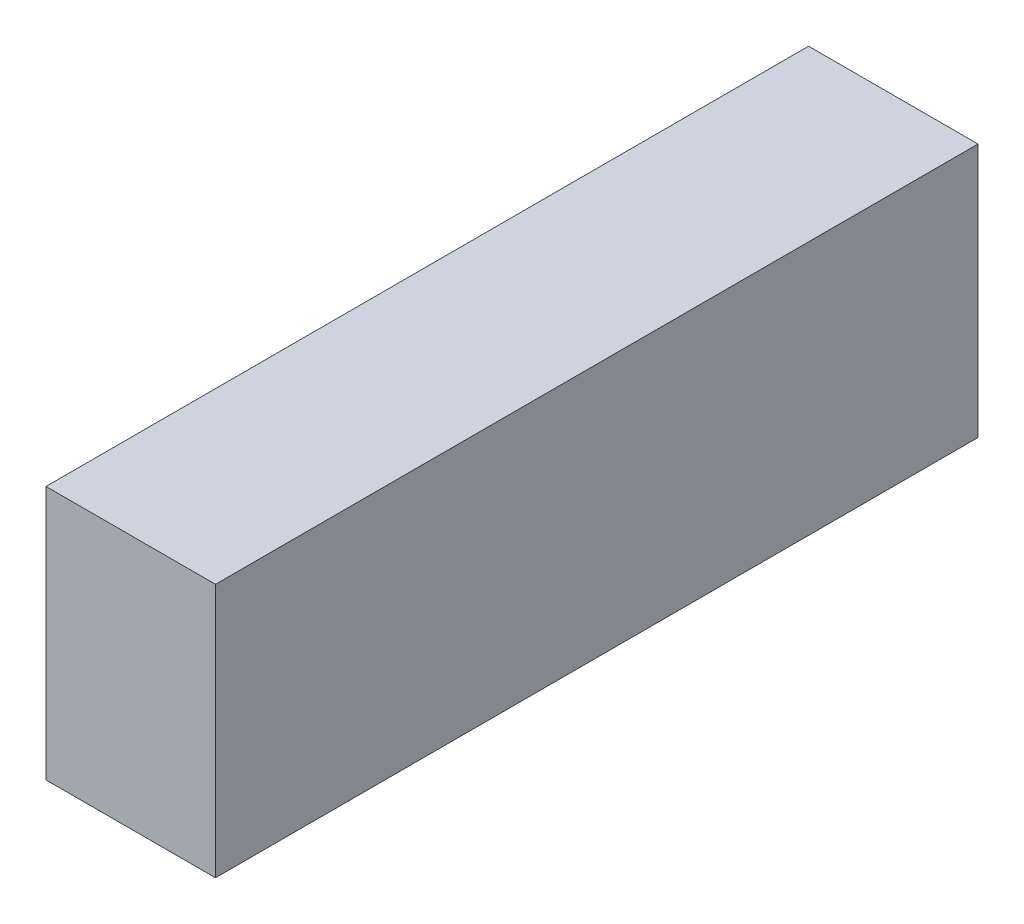
from build123d import *

# Parameters (mm, degrees)
SKETCH1_W           = 8.466666666
SKETCH1_H           = 12.7
BOSS_EXTRUDE1_DEPTH = 38.1


with BuildPart() as part:
    # Sketch1 → Boss-Extrude1 (new body)
    with BuildSketch(Plane.XY):
        Rectangle(SKETCH1_W, SKETCH1_H)
    extrude(amount=BOSS_EXTRUDE1_DEPTH)


solid = part.part
